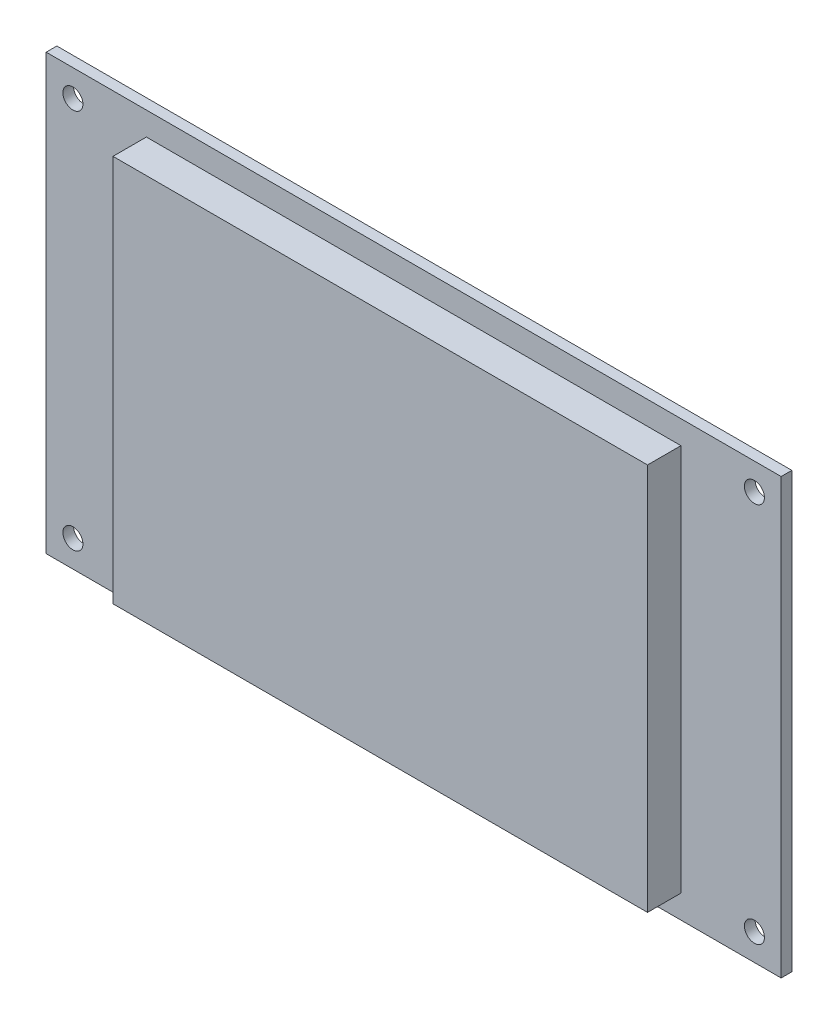
from build123d import *

# Parameters (mm, degrees)
SKETCH1_W           = 110
SKETCH1_H           = 65
SKETCH1_R           = 1.5
BOSS_EXTRUDE1_DEPTH = 1.6
SKETCH1_3_W         = 80
SKETCH1_3_H         = 58
BOSS_EXTRUDE2_DEPTH = 5


with BuildPart() as part:
    # Sketch1 → Boss-Extrude1 (new body)
    with BuildSketch(Plane.XY):
        Rectangle(SKETCH1_W, SKETCH1_H)
        with Locations((-51, -28.5)):
            Circle(SKETCH1_R, mode=Mode.SUBTRACT)
        with Locations((51, -28.5)):
            Circle(SKETCH1_R, mode=Mode.SUBTRACT)
        with Locations((-51, 28.5)):
            Circle(SKETCH1_R, mode=Mode.SUBTRACT)
        with Locations((51, 28.5)):
            Circle(SKETCH1_R, mode=Mode.SUBTRACT)
    extrude(amount=-BOSS_EXTRUDE1_DEPTH)

    # Sketch1_3 → Boss-Extrude2 (add)
    with BuildSketch(Plane.XY):
        Rectangle(SKETCH1_3_W, SKETCH1_3_H)
    extrude(amount=BOSS_EXTRUDE2_DEPTH)


solid = part.part
